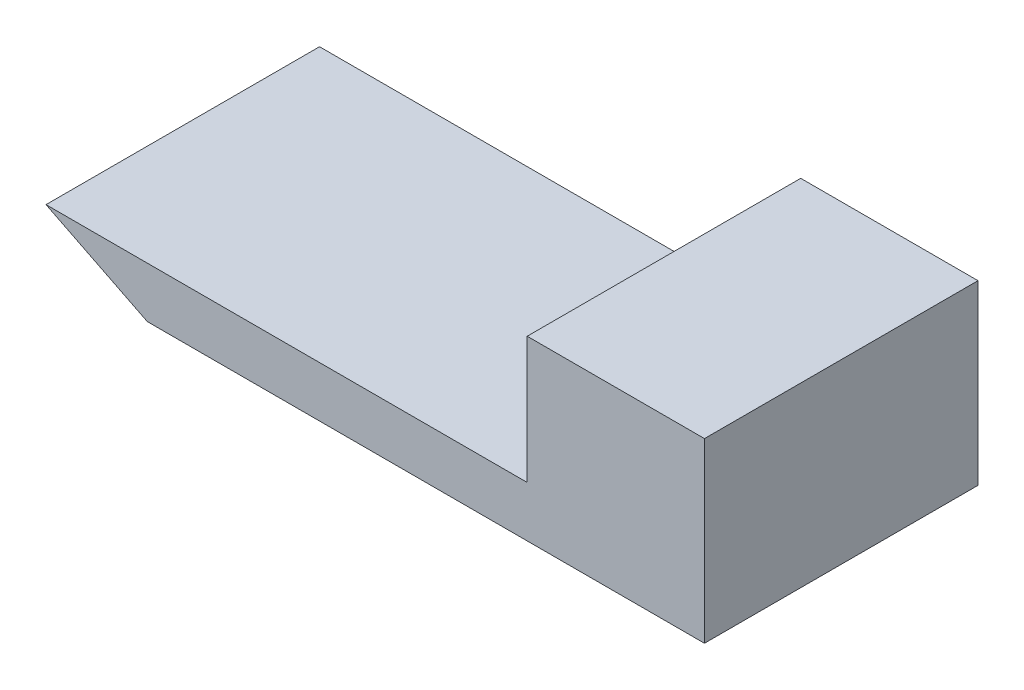
from build123d import *

# Parameters (mm, degrees)
SALIENTE_EXTRUIR1_DEPTH = 10.8


with BuildPart() as part:
    # Croquis1 → Saliente-Extruir1 (new body)
    with BuildSketch(Plane.XY):
        Polygon((-41.386126084, 15.454256189), (-41.386126084, 13.454256189), (-63.386126084, 13.454256189), (-67.386126084, 15.454256189), (-48.386126084, 15.454256189), (-48.386126084, 20.454256189), (-41.386126084, 20.454256189), align=None)
    extrude(amount=SALIENTE_EXTRUIR1_DEPTH)


solid = part.part
